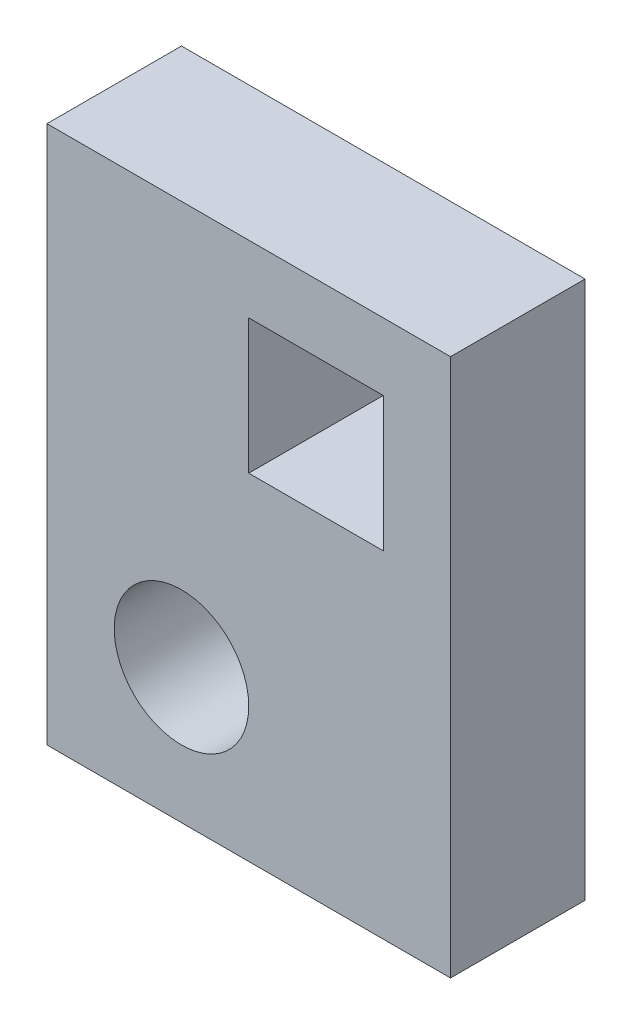
from build123d import *

# Parameters (mm, degrees)
SKETCH1_W           = 76.2
SKETCH1_H           = 101.6
SKETCH1_R           = 12.7
SKETCH1_W_2         = 25.4
SKETCH1_H_2         = 25.4
BOSS_EXTRUDE1_DEPTH = 25.4


with BuildPart() as part:
    # Sketch1 → Boss-Extrude1 (new body)
    with BuildSketch(Plane.XY):
        with Locations((38.1, 50.8)):
            Rectangle(SKETCH1_W, SKETCH1_H)
        with Locations((25.4, 25.4)):
            Circle(SKETCH1_R, mode=Mode.SUBTRACT)
        with Locations((50.8, 76.2)):
            Rectangle(SKETCH1_W_2, SKETCH1_H_2, mode=Mode.SUBTRACT)
    extrude(amount=BOSS_EXTRUDE1_DEPTH)


solid = part.part
